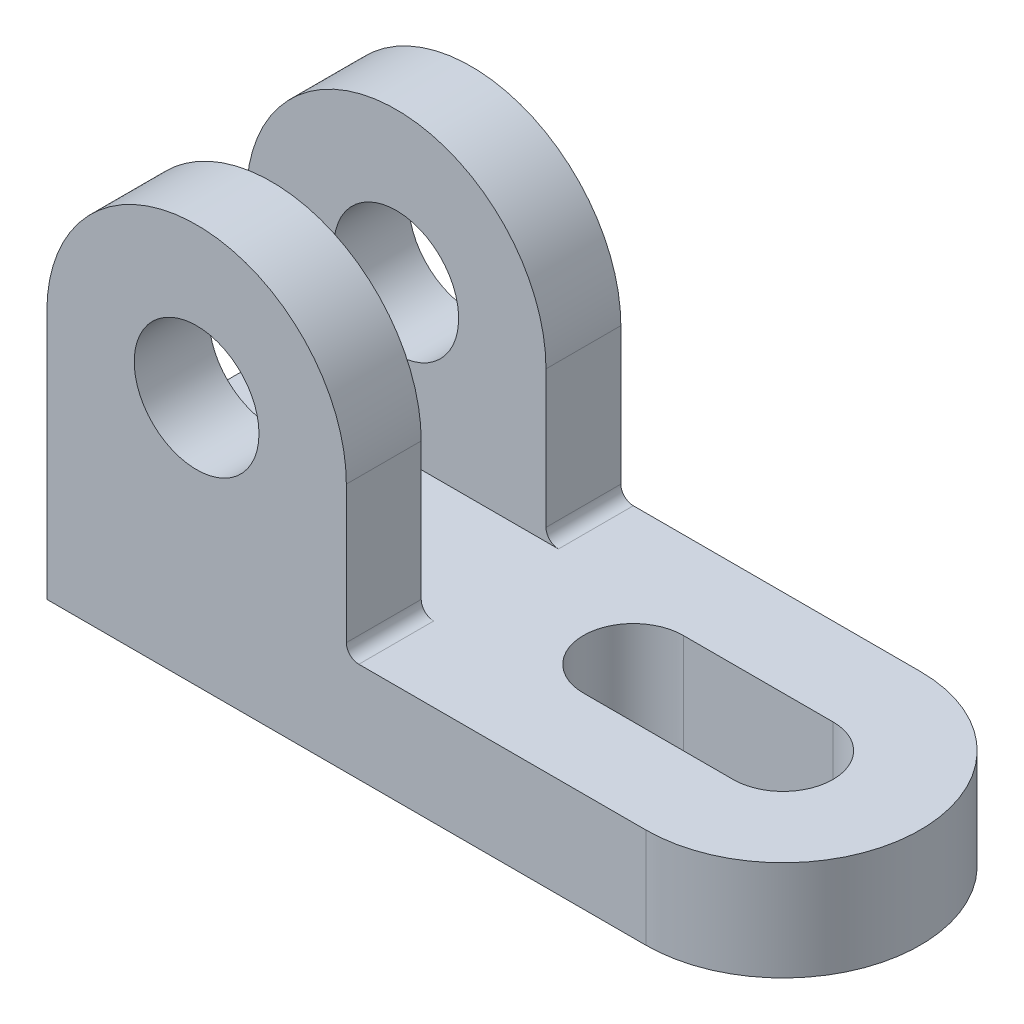
from build123d import *

# Parameters (mm, degrees)
BOSS_EXTRUDE1_DEPTH = 16
CUT_EXTRUDE2_DEPTH  = 16
SKETCH5_R           = 10
BOSS_EXTRUDE3_DEPTH = 12
SKETCH7_R           = 10
BOSS_EXTRUDE4_DEPTH = 12


with BuildPart() as part:
    # Sketch2 → Boss-Extrude1 (new body)
    with BuildSketch(Plane(origin=(0, 0, 0), x_dir=(1, 0, 0), z_dir=(0, 1, 0))):
        with BuildLine():
            Line((-48, 22), (48, 22))
            ThreePointArc((48, 22), (70, 0), (48, -22))
            Line((48, -22), (-48, -22))
            Line((-48, -22), (-48, 22))
        make_face()
    extrude(amount=BOSS_EXTRUDE1_DEPTH)

    # Sketch3 → Cut-Extrude2 (cut)
    with BuildSketch(Plane(origin=(0, 16, 0), x_dir=(1, 0, 0), z_dir=(0, 1, 0))):
        with BuildLine():
            Line((48, -8), (24, -8))
            ThreePointArc((24, -8), (16, 0), (24, 8))
            Line((24, 8), (48, 8))
            ThreePointArc((48, 8), (56, 0), (48, -8))
        make_face()
    extrude(amount=-CUT_EXTRUDE2_DEPTH, mode=Mode.SUBTRACT)

    # Sketch5 → Boss-Extrude3 (add)
    with BuildSketch(Plane.XY.offset(22)):
        with BuildLine():
            Line((-48, 40), (-48, 16))
            Line((-48, 16), (2, 16))
            ThreePointArc((2, 16), (0.585786438, 16.585786438), (0, 18))
            Line((0, 18), (0, 40))
            ThreePointArc((0, 40), (-24, 64), (-48, 40))
        make_face()
        with Locations((-24, 40)):
            Circle(SKETCH5_R, mode=Mode.SUBTRACT)
    extrude(amount=-BOSS_EXTRUDE3_DEPTH)

    # Sketch7 → Boss-Extrude4 (add)
    with BuildSketch(Plane(origin=(0, 0, -22), x_dir=(-1, 0, 0), z_dir=(0, 0, -1))):
        with BuildLine():
            Line((-2, 16), (48, 16))
            Line((48, 16), (48, 40))
            ThreePointArc((48, 40), (24, 64), (0, 40))
            Line((0, 40), (0, 18))
            ThreePointArc((0, 18), (-0.585786438, 16.585786438), (-2, 16))
        make_face()
        with Locations((24, 40)):
            Circle(SKETCH7_R, mode=Mode.SUBTRACT)
    extrude(amount=-BOSS_EXTRUDE4_DEPTH)


solid = part.part
